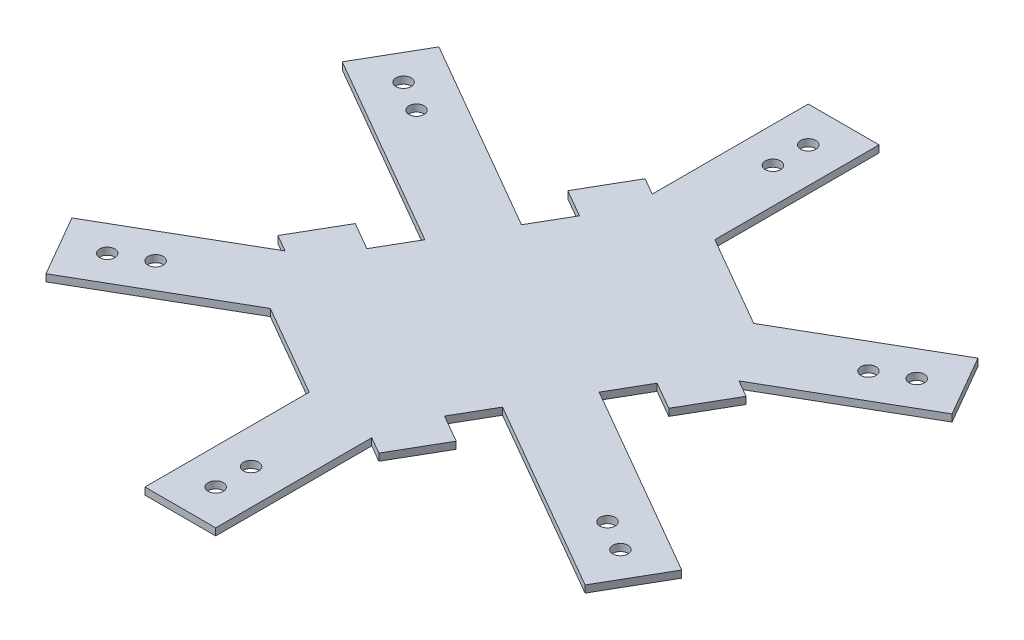
from build123d import *

# Parameters (mm, degrees)
BOSS_EXTRUDE2_DEPTH = 2
SKETCH2_R           = 2.15
CUT_EXTRUDE1_DEPTH  = 10
CUT_EXTRUDE3_DEPTH  = 30
BOSS_EXTRUDE4_DEPTH = 2
SKETCH9_W           = 20
SKETCH9_H           = 40
BOSS_EXTRUDE5_DEPTH = 2
CUT_EXTRUDE4_DEPTH  = 2
BOSS_EXTRUDE6_DEPTH = 2
BOSS_EXTRUDE7_DEPTH = 2
CUT_EXTRUDE5_DEPTH  = 2


with BuildPart() as part:
    # Sketch1 → Boss-Extrude2 (new body)
    with BuildSketch(Plane(origin=(0, 0, 0), x_dir=(1, 0, 0), z_dir=(0, 1, 0))):
        Polygon((102.5, 0), (51.25, 88.767603888), (-51.25, 88.767603888), (-102.5, 0), (-51.25, -88.767603888), (51.25, -88.767603888), align=None)
        Polygon((73.632486541, 0), (36.81624327, 63.767603888), (10, 63.767603888), (10, 45.767603888), (30, 45.767603888), (30, -45.767603888), (10, -45.767603888), (10, -63.767603888), (36.81624327, -63.767603888), align=None, mode=Mode.SUBTRACT)
        Polygon((-10, 63.767603888), (-36.81624327, 63.767603888), (-73.632486541, 0), (-36.81624327, -63.767603888), (-10, -63.767603888), (-10, -45.767603888), (-30, -45.767603888), (-30, 45.767603888), (-10, 45.767603888), align=None, mode=Mode.SUBTRACT)
    extrude(amount=BOSS_EXTRUDE2_DEPTH)

    # Sketch2 → Cut-Extrude1 (cut)
    with BuildSketch(Plane(origin=(0, 2, 0), x_dir=(1, 0, 0), z_dir=(0, 1, 0))):
        with Locations((-72.544872981, -41.883801944)):
            Circle(SKETCH2_R)
        with Locations((-63.884618943, -36.883801944)):
            Circle(SKETCH2_R)
        with Locations((-72.544872981, 41.883801944)):
            Circle(SKETCH2_R)
        with Locations((-63.884618943, 36.883801944)):
            Circle(SKETCH2_R)
        with Locations((0, 83.767603888)):
            Circle(SKETCH2_R)
        with Locations((0, 73.767603888)):
            Circle(SKETCH2_R)
        with Locations((72.544872981, 41.883801944)):
            Circle(SKETCH2_R)
        with Locations((63.884618943, 36.883801944)):
            Circle(SKETCH2_R)
        with Locations((72.544872981, -41.883801944)):
            Circle(SKETCH2_R)
        with Locations((63.884618943, -36.883801944)):
            Circle(SKETCH2_R)
        with Locations((0, -83.767603888)):
            Circle(SKETCH2_R)
        with Locations((0, -73.767603888)):
            Circle(SKETCH2_R)
    extrude(amount=-CUT_EXTRUDE1_DEPTH, mode=Mode.SUBTRACT)

    # Sketch7 → Cut-Extrude3 (cut)
    with BuildSketch(Plane.XZ):
        Polygon((73.632486541, 0), (36.81624327, 63.767603888), (-36.81624327, 63.767603888), (-73.632486541, 0), (-36.81624327, -63.767603888), (36.81624327, -63.767603888), align=None)
    extrude(amount=-CUT_EXTRUDE3_DEPTH, mode=Mode.SUBTRACT)



with BuildPart() as body_2:
    # Sketch8 → Boss-Extrude4 (new body)
    with BuildSketch(Plane.XZ):
        Polygon((2.980762114, 54.837168574), (-23, 39.837168574), (0, 0), (25.980762114, 15), align=None)
        Polygon((-23, 39.837168574), (-48.980762114, 24.837168574), (-2.980762114, -54.837168574), (48.980762114, -24.837168574), (25.980762114, 15), (0, 0), align=None)
    extrude(amount=-BOSS_EXTRUDE4_DEPTH)


with BuildPart() as part_1:
    add(part.part)

    add(body_2.part)  # Boss-Extrude5 merges body 2
    # Sketch9 → Boss-Extrude5 (add)
    with BuildSketch(Plane(origin=(0, 0, 0), x_dir=(-1, 0, 0), z_dir=(0, -1, 0))):
        Polygon((60.224364905, -23.223547906), (25.583348754, -3.223547906), (15.583348754, -20.544055982), (50.224364905, -40.544055982), align=None)
        with Locations((0, -43.767603888)):
            Rectangle(SKETCH9_W, SKETCH9_H)
        Polygon((-60.224364905, -23.223547906), (-25.583348754, -3.223547906), (-15.583348754, -20.544055982), (-50.224364905, -40.544055982), align=None)
        Polygon((-50.224364905, 40.544055982), (-15.583348754, 20.544055982), (-25.583348754, 3.223547906), (-60.224364905, 23.223547906), align=None)
        with Locations((0, 43.767603888)):
            Rectangle(SKETCH9_W, SKETCH9_H)
        Polygon((60.224364905, 23.223547906), (25.583348754, 3.223547906), (15.583348754, 20.544055982), (50.224364905, 40.544055982), align=None)
    extrude(amount=-BOSS_EXTRUDE5_DEPTH)

    # Sketch10 → Cut-Extrude4 (cut)
    with BuildSketch(Plane(origin=(0, 0, 0), x_dir=(-1, 0, 0), z_dir=(0, -1, 0))):
        Polygon((60.224364905, -23.223547906), (98.115262944, -45.099868089), (121.783609118, 0), (103.941012458, 48.463366139), (60.224364905, 23.223547906), align=None)
        Polygon((10, -107.520244253), (60.891804559, -105.467699261), (93.941012458, -65.783874214), (50.224364905, -40.544055982), (10, -63.767603888), align=None)
        Polygon((-88.115262944, -62.420376164), (-60.891804559, -105.467699261), (-10, -114.247240353), (-10, -63.767603888), (-50.224364905, -40.544055982), align=None)
        Polygon((-98.115262944, 45.099868089), (-121.783609118, 0), (-103.941012458, -48.463366139), (-60.224364905, -23.223547906), (-60.224364905, 23.223547906), align=None)
        Polygon((-10, 107.520244253), (-60.891804559, 105.467699261), (-93.941012458, 65.783874214), (-50.224364905, 40.544055982), (-10, 63.767603888), align=None)
        Polygon((88.115262944, 62.420376164), (60.891804559, 105.467699261), (10, 114.247240353), (10, 63.767603888), (50.224364905, 40.544055982), align=None)
    extrude(amount=-CUT_EXTRUDE4_DEPTH, mode=Mode.SUBTRACT)

    # Sketch12 → Boss-Extrude6 (add)
    with BuildSketch(Plane.XZ):
        Polygon((-81.205127019, -46.883801944), (-86.205127019, -38.223547906), (-81.875, -35.723547906), (-71.875, -53.044055982), (-76.205127019, -55.544055982), align=None)
        Polygon((-81.205127019, 46.883801944), (-86.205127019, 38.223547906), (-81.875, 35.723547906), (-71.875, 53.044055982), (-76.205127019, 55.544055982), align=None)
        Polygon((0, 93.767603888), (-10, 93.767603888), (-10, 88.767603888), (10, 88.767603888), (10, 93.767603888), align=None)
        Polygon((81.205127019, 46.883801944), (76.205127019, 55.544055982), (71.875, 53.044055982), (81.875, 35.723547906), (86.205127019, 38.223547906), align=None)
        Polygon((81.205127019, -46.883801944), (86.205127019, -38.223547906), (81.875, -35.723547906), (71.875, -53.044055982), (76.205127019, -55.544055982), align=None)
        Polygon((0, -93.767603888), (10, -93.767603888), (10, -88.767603888), (-10, -88.767603888), (-10, -93.767603888), align=None)
    extrude(amount=-BOSS_EXTRUDE6_DEPTH)

    # Sketch14 → Boss-Extrude7 (add)
    with BuildSketch(Plane(origin=(0, 2, 0), x_dir=(1, 0, 0), z_dir=(0, 1, 0))):
        Polygon((-18.239092363, 54.408965344), (-26.239092363, 40.552558883), (-14.980762114, 34.052558883), (-10, 42.679491924), (-10, 49.65212315), align=None)
        Polygon((41.961524227, 12.679491924), (36.980762114, 4.052558883), (48.239092363, -2.447441117), (56.239092363, 11.408965344), (48, 16.165807537), align=None)
        Polygon((26.239092363, -40.552558883), (14.980762114, -34.052558883), (10, -42.679491924), (10, -49.65212315), (18.239092363, -54.408965344), align=None)
        Polygon((-36.980762114, -4.052558883), (-48.239092363, 2.447441117), (-56.239092363, -11.408965344), (-48, -16.165807537), (-41.961524227, -12.679491924), align=None)
    extrude(amount=-BOSS_EXTRUDE7_DEPTH)

    # Sketch15 → Cut-Extrude5 (cut)
    with BuildSketch(Plane(origin=(0, 2, 0), x_dir=(1, 0, 0), z_dir=(0, 1, 0))):
        Polygon((-18.239092363, 54.408965344), (-14.774990748, 52.408965344), (-22.774990748, 38.552558883), (-26.239092363, 40.552558883), align=None)
        Polygon((-44.774990748, 0.447441117), (-48.239092363, 2.447441117), (-56.239092363, -11.408965344), (-52.774990748, -13.408965344), align=None)
        Polygon((18.239092363, -54.408965344), (14.774990748, -52.408965344), (22.774990748, -38.552558883), (26.239092363, -40.552558883), align=None)
        Polygon((44.774990748, -0.447441117), (48.239092363, -2.447441117), (56.239092363, 11.408965344), (52.774990748, 13.408965344), align=None)
    extrude(amount=-CUT_EXTRUDE5_DEPTH, mode=Mode.SUBTRACT)


solid = part_1.part
